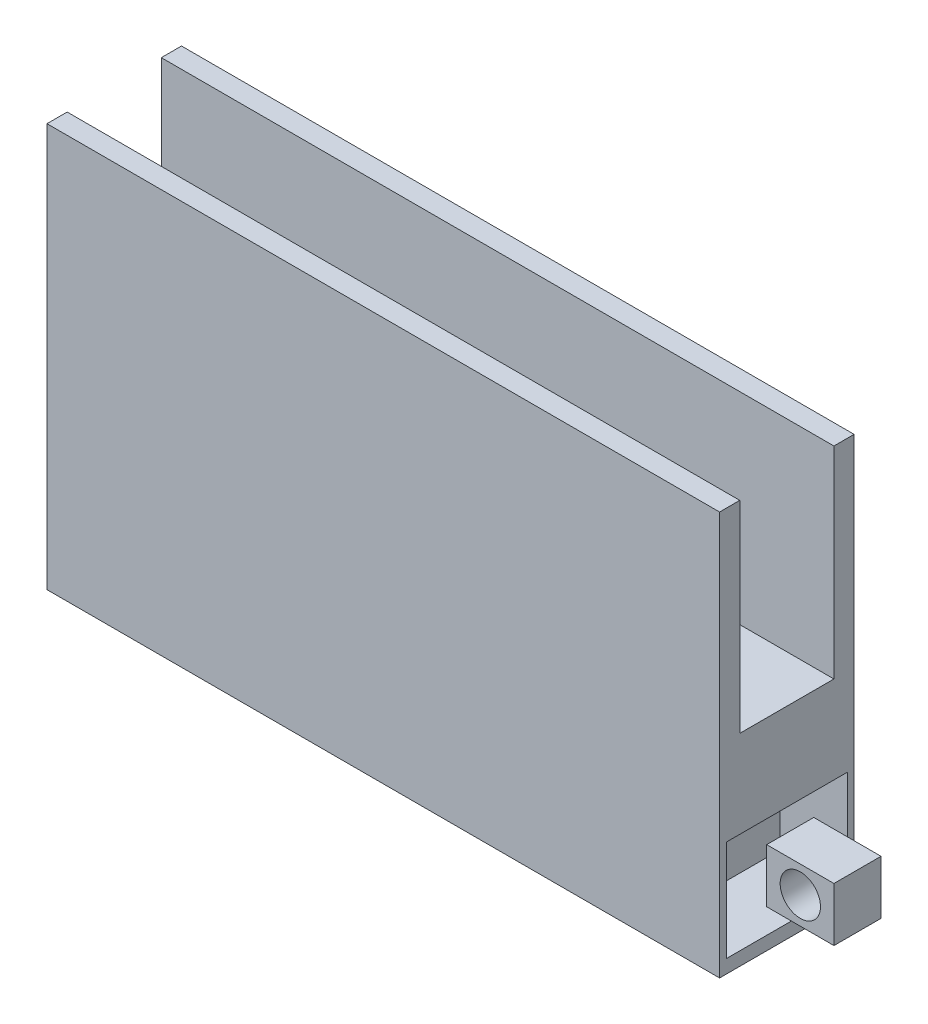
from build123d import *

# Parameters (mm, degrees)
SKETCH2_W            = 10
SKETCH2_H            = 2
BOSS_EXTRUDE6_DEPTH  = 2
SKETCH7_W            = 0.7
SKETCH7_H            = 0.8
BOSS_EXTRUDE9_DEPTH  = 1
SKETCH8_R            = 0.3
CUT_EXTRUDE1_DEPTH   = 1
SKETCH12_W           = 10
SKETCH12_H           = 2
BOSS_EXTRUDE13_DEPTH = 4
SKETCH13_W           = 1.8
SKETCH13_H           = 1.5
CUT_EXTRUDE5_DEPTH   = 1
SKETCH14_W           = 10
SKETCH14_H           = 1.4
CUT_EXTRUDE7_DEPTH   = 3
SKETCH15_W           = 1.4
SKETCH15_H           = 1.4
CUT_EXTRUDE9_DEPTH   = 4
SKETCH16_W           = 3
SKETCH16_H           = 1.4
CUT_EXTRUDE10_DEPTH  = 1.639962


with BuildPart() as part:
    # Sketch2 → Boss-Extrude6 (new body)
    with BuildSketch(Plane.XY):
        with Locations((5, 1)):
            Rectangle(SKETCH2_W, SKETCH2_H)
    extrude(amount=BOSS_EXTRUDE6_DEPTH)

    # Sketch7 → Boss-Extrude9 (add)
    with BuildSketch(Plane(origin=(10, 0, 0), x_dir=(0, 0, -1), z_dir=(1, 0, 0))):
        with Locations((-0.95, 0.967257018)):
            Rectangle(SKETCH7_W, SKETCH7_H)
    extrude(amount=BOSS_EXTRUDE9_DEPTH)

    # Sketch8 → Cut-Extrude1 (cut)
    with BuildSketch(Plane.XY.offset(1.3)):
        with Locations((10.5, 0.967257018)):
            Circle(SKETCH8_R)
    extrude(amount=-CUT_EXTRUDE1_DEPTH, mode=Mode.SUBTRACT)

    # Sketch12 → Boss-Extrude13 (add)
    with BuildSketch(Plane(origin=(0, 2, 0), x_dir=(1, 0, 0), z_dir=(0, 1, 0))):
        with Locations((5, -1)):
            Rectangle(SKETCH12_W, SKETCH12_H)
    extrude(amount=BOSS_EXTRUDE13_DEPTH)

    # Sketch13 → Cut-Extrude5 (cut)
    with BuildSketch(Plane(origin=(10, 0, 0), x_dir=(0, 0, -1), z_dir=(1, 0, 0))):
        with Locations((-1, 0.95)):
            Rectangle(SKETCH13_W, SKETCH13_H)
    extrude(amount=-CUT_EXTRUDE5_DEPTH, mode=Mode.SUBTRACT)

    # Sketch14 → Cut-Extrude7 (cut)
    with BuildSketch(Plane(origin=(0, 6, 0), x_dir=(1, 0, 0), z_dir=(0, 1, 0))):
        with Locations((5, -1)):
            Rectangle(SKETCH14_W, SKETCH14_H)
    extrude(amount=-CUT_EXTRUDE7_DEPTH, mode=Mode.SUBTRACT)

    # Sketch15 → Cut-Extrude9 (cut)
    with BuildSketch(Plane.ZY):
        with Locations((1, 0.939962181)):
            Rectangle(SKETCH15_W, SKETCH15_H)
    extrude(amount=-CUT_EXTRUDE9_DEPTH, mode=Mode.SUBTRACT)

    # Sketch16 → Cut-Extrude10 (cut)
    with BuildSketch(Plane.XZ):
        with Locations((1.74, 1)):
            Rectangle(SKETCH16_W, SKETCH16_H)
    extrude(amount=-CUT_EXTRUDE10_DEPTH, mode=Mode.SUBTRACT)


solid = part.part
